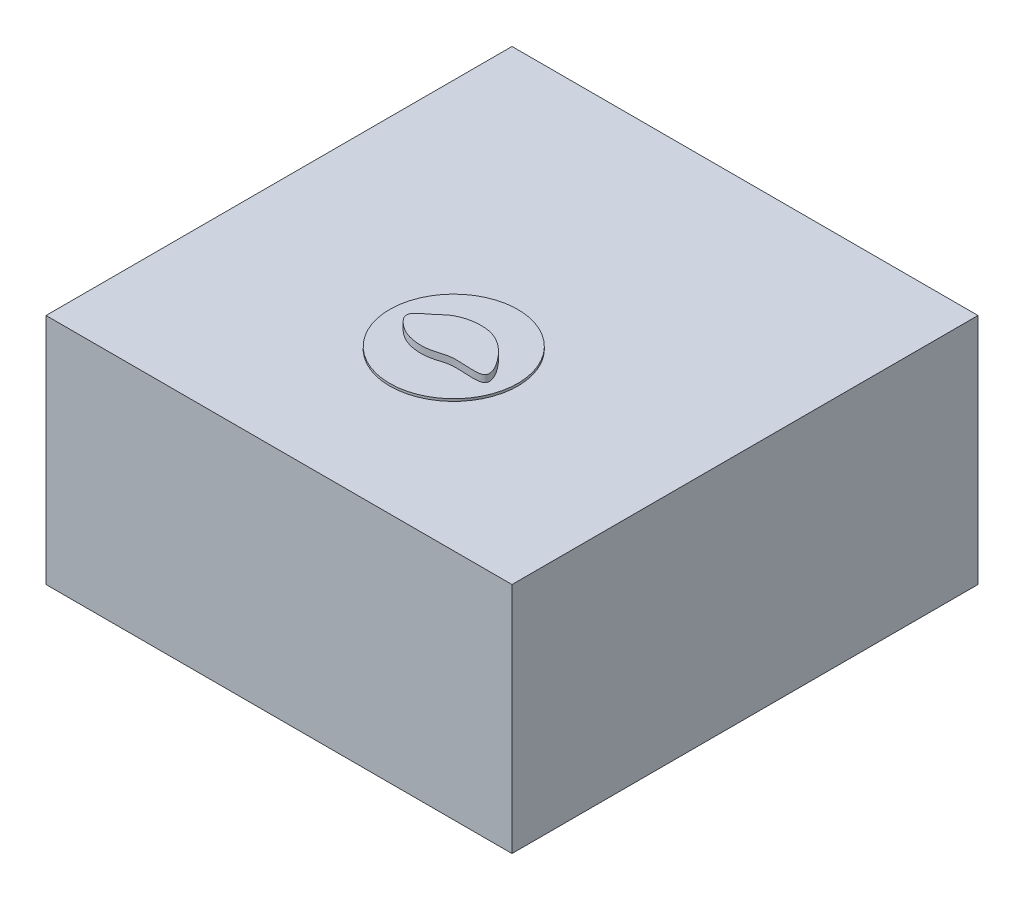
from build123d import *

# Parameters (mm, degrees)
SKETCH1_W             = 20
SKETCH1_H             = 10
BOSS_EXTRUDE1_DEPTH   = 20
SKETCH2_R             = 0.5
SKETCH5_R             = 2.75
BOSS_EXTRUDE4_DEPTH   = 0.1
SKETCH8_R             = 0.005
BOSS_EXTRUDE5_DEPTH   = 0.1
BOSS_EXTRUDE5_2_DEPTH = 0.1
BOSS_EXTRUDE5_3_DEPTH = 0.1
BOSS_EXTRUDE5_4_DEPTH = 0.1
BOSS_EXTRUDE5_5_DEPTH = 0.1
BOSS_EXTRUDE5_6_DEPTH = 0.1
BOSS_EXTRUDE5_7_DEPTH = 0.1
BOSS_EXTRUDE5_8_DEPTH = 0.1
BOSS_EXTRUDE5_9_DEPTH = 0.1
SLICE_2_DEPTH         = 0.3


with BuildPart() as part:
    # Sketch1 → Boss-Extrude1 (new body)
    with BuildSketch(Plane.XY):
        Rectangle(SKETCH1_W, SKETCH1_H)
    extrude(amount=BOSS_EXTRUDE1_DEPTH)


with BuildPart() as body_2:
    # ag/agcl electrodes: sweep along a path in Sketch3
    with BuildLine(Plane(origin=(7.5, 0, 0), x_dir=(0, 0, -1), z_dir=(1, 0, 0))) as ag_agcl_electrodes_path:
        Line((-20, 4), (-5, 4))
        ThreePointArc((-5, 4), (-4.292893219, 4.292893219), (-4, 5))
    # Sketch2 → ag/agcl electrodes (sweep)
    with BuildSketch(Plane.XY.offset(20)):
        with Locations((-7.5, 4)):
            Circle(SKETCH2_R)
        with Locations((7.5, 4)):
            Circle(SKETCH2_R)
    sweep(path=ag_agcl_electrodes_path.line)


with BuildPart() as body_3:
    # Sketch5 → Boss-Extrude4 (new body)
    with BuildSketch(Plane(origin=(0, 5, 0), x_dir=(1, 0, 0), z_dir=(0, 1, 0))):
        with Locations((0, -12.5)):
            Circle(SKETCH5_R)
    extrude(amount=BOSS_EXTRUDE4_DEPTH)


with BuildPart() as body_4:
    # Sketch8 → Boss-Extrude5 (new body)
    with BuildSketch(Plane(origin=(0, 5.1, 0), x_dir=(-1, 0, 0), z_dir=(0, -1, 0))):
        with Locations((0, -12.5)):
            Circle(SKETCH8_R)
    extrude(amount=BOSS_EXTRUDE5_DEPTH)


with BuildPart() as body_5:
    # Sketch8 → Boss-Extrude5 2 (new body)
    with BuildSketch(Plane(origin=(0, 5.1, 0), x_dir=(-1, 0, 0), z_dir=(0, -1, 0))):
        with Locations((0.5, -12.5)):
            Circle(SKETCH8_R)
    extrude(amount=BOSS_EXTRUDE5_2_DEPTH)


with BuildPart() as body_6:
    # Sketch8 → Boss-Extrude5 3 (new body)
    with BuildSketch(Plane(origin=(0, 5.1, 0), x_dir=(-1, 0, 0), z_dir=(0, -1, 0))):
        with Locations((0.5, -12)):
            Circle(SKETCH8_R)
    extrude(amount=BOSS_EXTRUDE5_3_DEPTH)


with BuildPart() as body_7:
    # Sketch8 → Boss-Extrude5 4 (new body)
    with BuildSketch(Plane(origin=(0, 5.1, 0), x_dir=(-1, 0, 0), z_dir=(0, -1, 0))):
        with Locations((0, -12)):
            Circle(SKETCH8_R)
    extrude(amount=BOSS_EXTRUDE5_4_DEPTH)


with BuildPart() as body_8:
    # Sketch8 → Boss-Extrude5 5 (new body)
    with BuildSketch(Plane(origin=(0, 5.1, 0), x_dir=(-1, 0, 0), z_dir=(0, -1, 0))):
        with Locations((0.5, -13)):
            Circle(SKETCH8_R)
    extrude(amount=BOSS_EXTRUDE5_5_DEPTH)


with BuildPart() as body_9:
    # Sketch8 → Boss-Extrude5 6 (new body)
    with BuildSketch(Plane(origin=(0, 5.1, 0), x_dir=(-1, 0, 0), z_dir=(0, -1, 0))):
        with Locations((0, -13)):
            Circle(SKETCH8_R)
    extrude(amount=BOSS_EXTRUDE5_6_DEPTH)


with BuildPart() as body_10:
    # Sketch8 → Boss-Extrude5 7 (new body)
    with BuildSketch(Plane(origin=(0, 5.1, 0), x_dir=(-1, 0, 0), z_dir=(0, -1, 0))):
        with Locations((-0.5, -13)):
            Circle(SKETCH8_R)
    extrude(amount=BOSS_EXTRUDE5_7_DEPTH)


with BuildPart() as body_11:
    # Sketch8 → Boss-Extrude5 8 (new body)
    with BuildSketch(Plane(origin=(0, 5.1, 0), x_dir=(-1, 0, 0), z_dir=(0, -1, 0))):
        with Locations((-0.5, -12)):
            Circle(SKETCH8_R)
    extrude(amount=BOSS_EXTRUDE5_8_DEPTH)


with BuildPart() as body_12:
    # Sketch8 → Boss-Extrude5 9 (new body)
    with BuildSketch(Plane(origin=(0, 5.1, 0), x_dir=(-1, 0, 0), z_dir=(0, -1, 0))):
        with Locations((-0.5, -12.5)):
            Circle(SKETCH8_R)
    extrude(amount=BOSS_EXTRUDE5_9_DEPTH)


with BuildPart() as body_13:
    # Sketch4 → slice 2 (new body)
    with BuildSketch(Plane(origin=(0, 5.1, 0), x_dir=(1, 0, 0), z_dir=(0, 1, 0))):
        with BuildLine():
            add(Edge.make_bspline(
                [(-1.329786825, -12.04709664), (-1.196342031, -11.939424685), (-0.824147777, -11.548957834), (0.251281573, -11.322574475), (1.372606671, -11.746573561), (2.652909809, -13.571837262), (0.780549472, -13.104467787), (-0.122057097, -13.506347246), (-0.994791107, -13.460960152), (-1.586432094, -13.116889112), (-2.086144249, -12.539169772), (-1.569499382, -12.240512354), (-1.329786825, -12.04709664)],
                knots=[0, 0, 0, 0, 0.049562645, 0.182817887, 0.303261475, 0.461561344, 0.613381106, 0.684437877, 0.79516613, 0.866564728, 0.910968514, 1, 1, 1, 1], degree=3))
        make_face()
    extrude(amount=SLICE_2_DEPTH)


solid = Compound([part.part, body_2.part, body_3.part, body_4.part, body_5.part, body_6.part, body_7.part, body_8.part, body_9.part, body_10.part, body_11.part, body_12.part, body_13.part])
